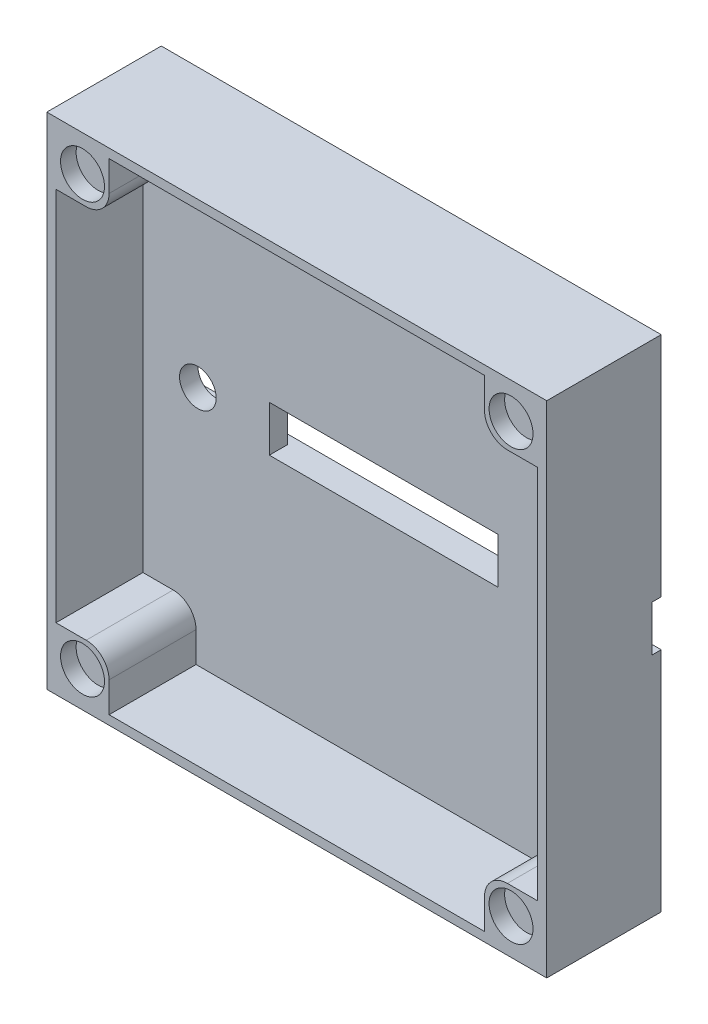
from build123d import *

# Parameters (mm, degrees)
SKICA1_W                 = 54.6
SKICA1_H                 = 54.6
P_IDAT_VYSUNUT_M2_DEPTH  = 3
SKICA4_W                 = 25
SKICA4_H                 = 5
ODEBRAT_VYSUNUT_M1_DEPTH = 2
SKICA5_W                 = 54.6
SKICA5_H                 = 5
ODEBRAT_VYSUNUT_M3_DEPTH = 1
SKICA14_W                = 52.6
SKICA14_H                = 1
P_IDAT_VYSUNUT_M9_DEPTH  = 9.5
SKICA17_R                = 2
ODEBRAT_VYSUNUT_M8_DEPTH = 4
SKICA19_W                = 6.8
SKICA19_H                = 6.8
P_IDAT_VYSUNUT_M10_DEPTH = 12.5
SKICA20_R                = 2.4
ODEBRAT_VYSUNUT_M9_DEPTH = 1.7
ZAOBLIT1_R               = 2.5


with BuildPart() as part:
    # Skica1 → Přidat vysunutím2 (new body)
    with BuildSketch(Plane.XY):
        Rectangle(SKICA1_W, SKICA1_H)
    extrude(amount=P_IDAT_VYSUNUT_M2_DEPTH)

    # Skica4 → Odebrat vysunutím1 (cut)
    with BuildSketch(Plane.XY.offset(3)):
        Rectangle(SKICA4_W, SKICA4_H)
    extrude(amount=-ODEBRAT_VYSUNUT_M1_DEPTH, mode=Mode.SUBTRACT)

    # Skica5 → Odebrat vysunutím3 (cut)
    with BuildSketch(Plane(origin=(0, 0, 0), x_dir=(-1, 0, 0), z_dir=(0, 0, -1))):
        Rectangle(SKICA5_W, SKICA5_H)
    extrude(amount=-ODEBRAT_VYSUNUT_M3_DEPTH, mode=Mode.SUBTRACT)

    # Skica14 → Přidat vysunutím9 (add)
    with BuildSketch(Plane.XY.offset(3)):
        Polygon((27.3, 27.3), (-27.3, 27.3), (-27.3, -27.3), (-26.3, -27.3), (-26.3, -26.3), (-26.3, 26.3), (26.3, 26.3), (26.3, -26.3), (26.3, -27.3), (27.3, -27.3), align=None)
        with Locations((0, -26.8)):
            Rectangle(SKICA14_W, SKICA14_H)
    extrude(amount=P_IDAT_VYSUNUT_M9_DEPTH)

    # Skica17 → Odebrat vysunutím8 (cut)
    with BuildSketch(Plane(origin=(0, 0, 1), x_dir=(-1, 0, 0), z_dir=(0, 0, -1))):
        with Locations((-20.3, 0)):
            Circle(SKICA17_R)
        with Locations((20.3, 0)):
            Circle(SKICA17_R)
    extrude(amount=-ODEBRAT_VYSUNUT_M8_DEPTH, mode=Mode.SUBTRACT)

    # Skica19 → Přidat vysunutím10 (add)
    with BuildSketch(Plane(origin=(0, 0, 0), x_dir=(-1, 0, 0), z_dir=(0, 0, -1))):
        with Locations((-23.9, 23.9)):
            Rectangle(SKICA19_W, SKICA19_H)
        with Locations((23.9, 23.9)):
            Rectangle(SKICA19_W, SKICA19_H)
        with Locations((-23.9, -23.9)):
            Rectangle(SKICA19_W, SKICA19_H)
        with Locations((23.9, -23.9)):
            Rectangle(SKICA19_W, SKICA19_H)
    extrude(amount=-P_IDAT_VYSUNUT_M10_DEPTH)

    # Skica20 → Odebrat vysunutím9 (cut)
    with BuildSketch(Plane.XY.offset(12.5)):
        with Locations((-23.4, -23.4)):
            Circle(SKICA20_R)
        with Locations((-23.4, 23.4)):
            Circle(SKICA20_R)
        with Locations((23.400280565, 23.4)):
            Circle(SKICA20_R)
        with Locations((23.400280565, -23.4)):
            Circle(SKICA20_R)
    extrude(amount=-ODEBRAT_VYSUNUT_M9_DEPTH, mode=Mode.SUBTRACT)

    # Zaoblit1
    zaoblit1_edges = [part.edges().sort_by_distance(p)[0] for p in [
        (-20.5, 20.5, 7.75),
        (20.5, -20.5, 7.75),
        (-20.5, -20.5, 7.75),
        (20.5, 20.5, 7.75),
    ]]
    fillet(zaoblit1_edges, radius=ZAOBLIT1_R)


solid = part.part
